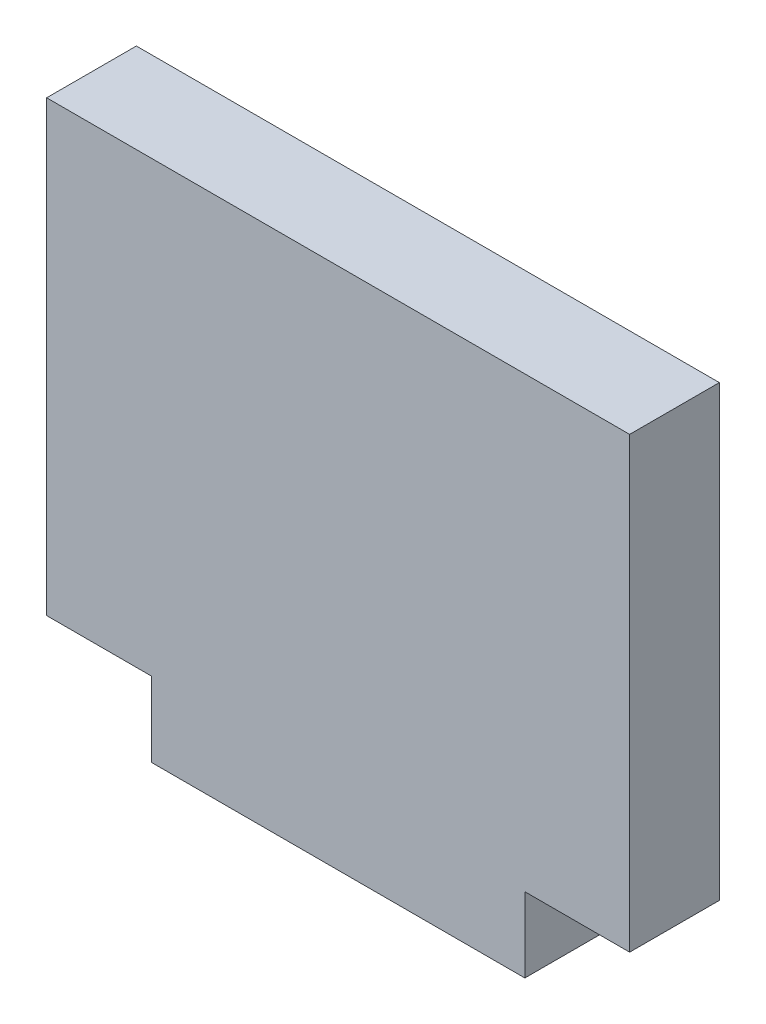
from build123d import *

# Parameters (mm, degrees)
ESQUISSE1_W        = 39
ESQUISSE1_H        = 30
ESQUISSE1_W_2      = 24.98
ESQUISSE1_H_2      = 5
BOSS_EXTRU_1_DEPTH = 6


with BuildPart() as part:
    # Esquisse1 → Boss.-Extru.1 (new body)
    with BuildSketch(Plane.XY):
        with Locations((0.543368541, 4.722975207)):
            Rectangle(ESQUISSE1_W, ESQUISSE1_H)
        with Locations((0.543368541, -12.777024793)):
            Rectangle(ESQUISSE1_W_2, ESQUISSE1_H_2)
    extrude(amount=BOSS_EXTRU_1_DEPTH)


solid = part.part
